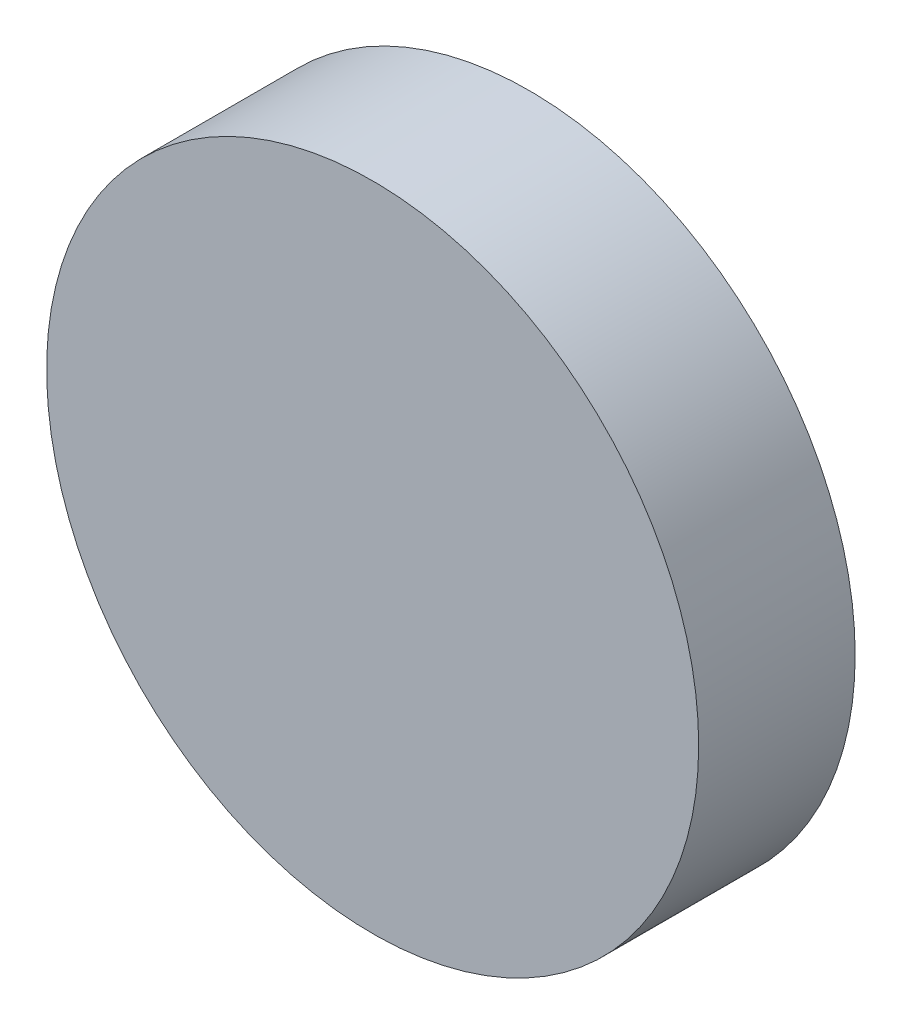
from build123d import *

# Parameters (mm, degrees)
SKETCH_1_R      = 12.5
EXTRUDE_1_DEPTH = 6


with BuildPart() as part:
    # 草图1 → 凸台-拉伸1 (new body)
    with BuildSketch(Plane.XY):
        Circle(SKETCH_1_R)
    extrude(amount=EXTRUDE_1_DEPTH)


solid = part.part
